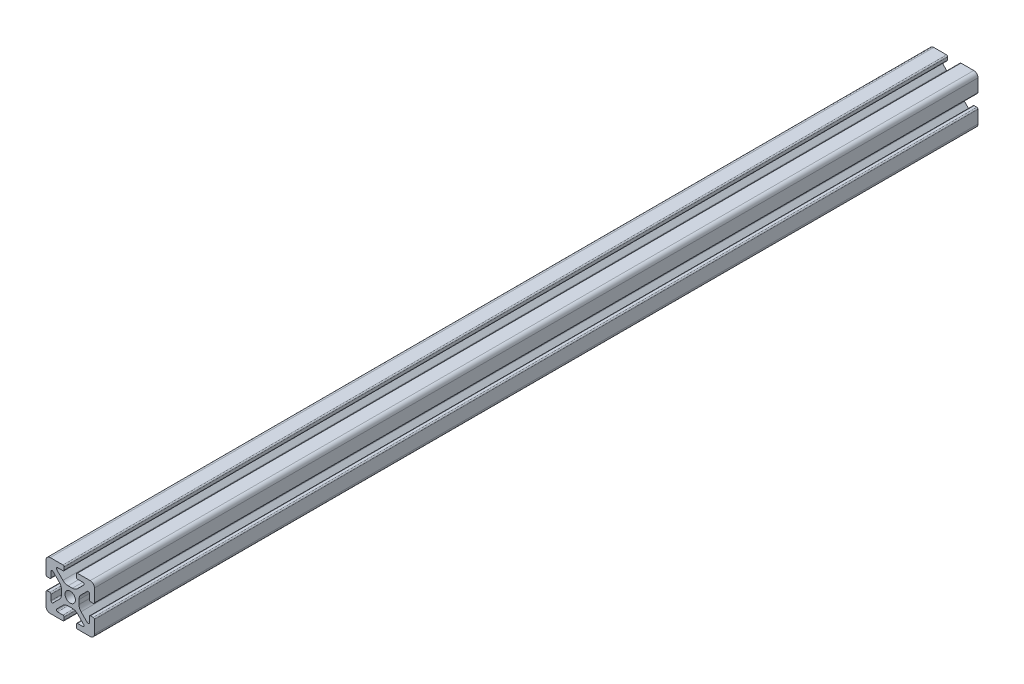
from build123d import *

# Parameters (mm, degrees)
BOSS_EXTRUDE1_DEPTH = 182.5


with BuildPart() as part:
    # Sketch4 → Boss-Extrude1 (new body, symmetric)
    with BuildSketch(Plane.XY):
        with BuildLine():
            Line((3, -10), (8.25, -10))
            ThreePointArc((8.25, -10), (9.487436867, -9.487436867), (10, -8.25))
            Line((10, -8.25), (10, -3))
            ThreePointArc((10, -3), (9.853553391, -2.646446609), (9.5, -2.5))
            Line((9.5, -2.5), (8.424621202, -2.5))
            ThreePointArc((8.424621202, -2.5), (8.071067812, -2.646446609), (7.924621202, -3))
            Line((7.924621202, -3), (7.924621202, -5.25))
            ThreePointArc((7.924621202, -5.25), (7.615962919, -5.711939766), (7.071067812, -5.603553391))
            Line((7.071067812, -5.603553391), (4.478679656, -3.011165235))
            ThreePointArc((4.478679656, -3.011165235), (3.828361402, -2.037895189), (3.6, -0.889844892))
            Line((3.6, -0.889844892), (3.6, 0))
            Line((3.6, 0), (2.15, 0))
            ThreePointArc((2.15, 0), (1.52027958, -1.52027958), (0, -2.15))
            Line((0, -2.15), (0, -3.6))
            Line((0, -3.6), (0.889844892, -3.6))
            ThreePointArc((0.889844892, -3.6), (2.037895189, -3.828361402), (3.011165235, -4.478679656))
            Line((3.011165235, -4.478679656), (5.603553391, -7.071067812))
            ThreePointArc((5.603553391, -7.071067812), (5.711939766, -7.615962919), (5.25, -7.924621202))
            Line((5.25, -7.924621202), (3, -7.924621202))
            ThreePointArc((3, -7.924621202), (2.646446609, -8.071067812), (2.5, -8.424621202))
            Line((2.5, -8.424621202), (2.5, -9.5))
            ThreePointArc((2.5, -9.5), (2.646446609, -9.853553391), (3, -10))
        make_face()
    extrude(amount=BOSS_EXTRUDE1_DEPTH, both=True)

    # Mirror1: part across plane


with BuildPart() as part_1:
    add(part.part)
    add(part.part.mirror(Plane(origin=(0, 0, 0), x_dir=(0, 0, 1), z_dir=(1, 0, 0))))

    # Mirror2: part across plane


with BuildPart() as part_2:
    add(part_1.part)
    add(part_1.part.mirror(Plane.ZX))


solid = part_2.part
